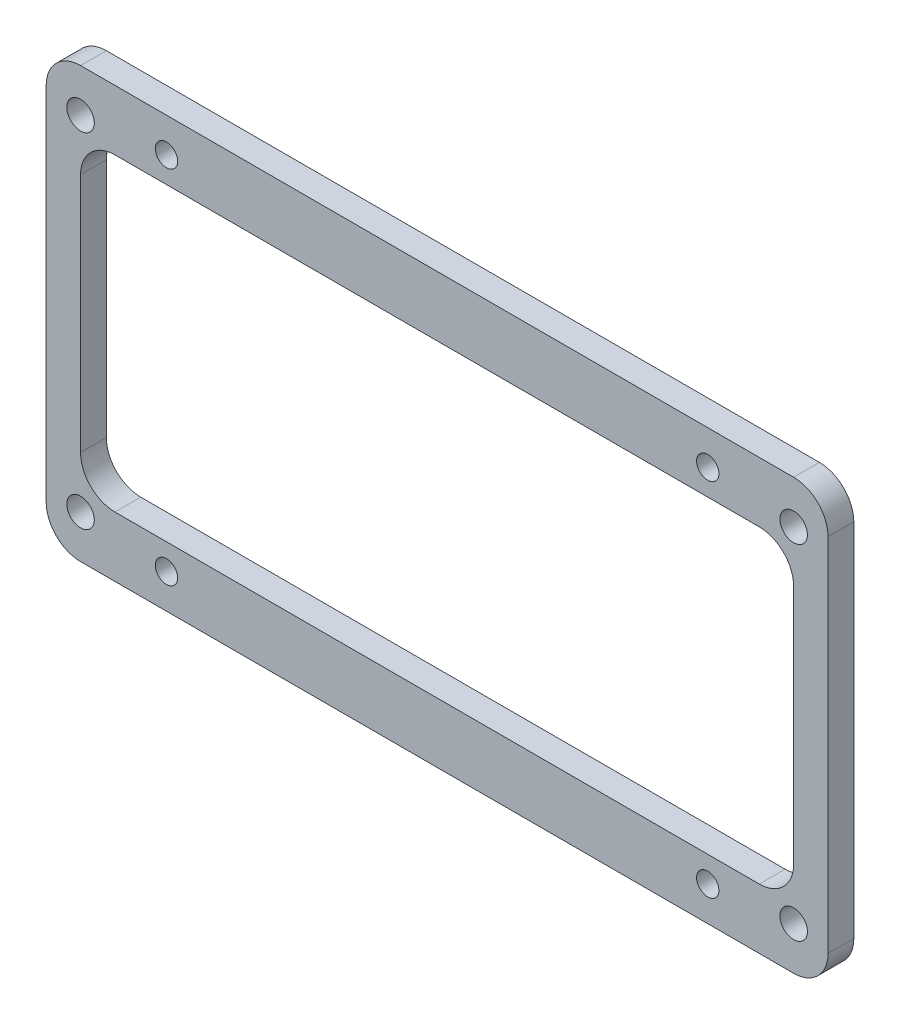
from build123d import *

# Parameters (mm, degrees)
SKETCH_1_W          = 91
SKETCH_1_H          = 50
SKETCH_1_W_2        = 83
SKETCH_1_H_2        = 36
EXTRUDE_1_DEPTH     = 3
SKETCH_2_R          = 1.3
CUT_EXTRUDE_1_DEPTH = 3
SKETCH_3_R          = 1.6
CUT_EXTRUDE_2_DEPTH = 3
FILLET_1_R          = 4
SKETCH_4_W          = 30
SKETCH_4_H          = 35
EXTRUDE_2_DEPTH     = 3
SKETCH_5_R          = 1.25
CUT_EXTRUDE_3_DEPTH = 10
FILLET_2_R          = 3
SKETCH_6_W          = 18
SKETCH_6_H          = 27
CUT_EXTRUDE_4_DEPTH = 10
FILLET_3_R          = 2
SKETCH_7_W          = 38
SKETCH_7_H          = 10
SKETCH_7_R          = 1.6
EXTRUDE_3_DEPTH     = 3
FILLET_4_R          = 2
FILLET_5_R          = 2
SKETCH_8_W          = 42
SKETCH_8_H          = 10
CUT_EXTRUDE_5_DEPTH = 10
SKETCH_9_W          = 30
SKETCH_9_H          = 41
CUT_EXTRUDE_6_DEPTH = 10


with BuildPart() as part:
    # 草图1 → 凸台-拉伸1 (new body)
    with BuildSketch(Plane.XY):
        Rectangle(SKETCH_1_W, SKETCH_1_H)
        Rectangle(SKETCH_1_W_2, SKETCH_1_H_2, mode=Mode.SUBTRACT)
    extrude(amount=EXTRUDE_1_DEPTH)

    # 草图2 → 切除-拉伸1 (cut)
    with BuildSketch(Plane.XY.offset(3)):
        with Locations((31.5, 21)):
            Circle(SKETCH_2_R)
        with Locations((31.5, -21)):
            Circle(SKETCH_2_R)
        with Locations((-31.5, -21)):
            Circle(SKETCH_2_R)
        with Locations((-31.5, 21)):
            Circle(SKETCH_2_R)
    extrude(amount=-CUT_EXTRUDE_1_DEPTH, mode=Mode.SUBTRACT)

    # 草图3 → 切除-拉伸2 (cut)
    with BuildSketch(Plane.XY.offset(3)):
        with Locations((41.5, 20)):
            Circle(SKETCH_3_R)
        with Locations((41.5, -20)):
            Circle(SKETCH_3_R)
        with Locations((-41.5, -20)):
            Circle(SKETCH_3_R)
        with Locations((-41.5, 20)):
            Circle(SKETCH_3_R)
    extrude(amount=-CUT_EXTRUDE_2_DEPTH, mode=Mode.SUBTRACT)

    # 圆角1
    fillet_1_edges = [part.edges().sort_by_distance(p)[0] for p in [
        (41.5, -18, 1.5),
        (41.5, 18, 1.5),
        (-41.5, 18, 1.5),
        (-41.5, -18, 1.5),
        (45.5, -25, 1.5),
        (-45.5, -25, 1.5),
        (-45.5, 25, 1.5),
        (45.5, 25, 1.5),
    ]]
    fillet(fillet_1_edges, radius=FILLET_1_R)

    # 草图4 → 凸台-拉伸2 (add)
    with BuildSketch(Plane(origin=(0, 0, 0), x_dir=(-1, 0, 0), z_dir=(0, 0, -1))):
        with Locations((-60.5, 0)):
            Rectangle(SKETCH_4_W, SKETCH_4_H)
    extrude(amount=-EXTRUDE_2_DEPTH)

    # 草图5 → 切除-拉伸3 (cut)
    with BuildSketch(Plane(origin=(0, 0, 0), x_dir=(-1, 0, 0), z_dir=(0, 0, -1))):
        with Locations((-70.5, -12)):
            Circle(SKETCH_5_R)
        with Locations((-70.5, 12)):
            Circle(SKETCH_5_R)
    extrude(amount=-CUT_EXTRUDE_3_DEPTH, mode=Mode.SUBTRACT)

    # 圆角2
    fillet_2_edges = [part.edges().sort_by_distance(p)[0] for p in [
        (45.5, 17.5, 1.5),
        (45.5, -17.5, 1.5),
        (75.5, -17.5, 1.5),
        (75.5, 17.5, 1.5),
    ]]
    fillet(fillet_2_edges, radius=FILLET_2_R)

    # 草图6 → 切除-拉伸4 (cut)
    with BuildSketch(Plane(origin=(0, 0, 0), x_dir=(-1, 0, 0), z_dir=(0, 0, -1))):
        with Locations((-57.5, 0)):
            Rectangle(SKETCH_6_W, SKETCH_6_H)
    extrude(amount=-CUT_EXTRUDE_4_DEPTH, mode=Mode.SUBTRACT)

    # 圆角3
    fillet_3_edges = [part.edges().sort_by_distance(p)[0] for p in [
        (66.5, -13.5, 1.5),
        (66.5, 13.5, 1.5),
        (48.5, 13.5, 1.5),
        (48.5, -13.5, 1.5),
    ]]
    fillet(fillet_3_edges, radius=FILLET_3_R)

    # 草图7 → 凸台-拉伸3 (add)
    with BuildSketch(Plane(origin=(0, 0, 0), x_dir=(-1, 0, 0), z_dir=(0, 0, -1))):
        with Locations((0, 30)):
            Rectangle(SKETCH_7_W, SKETCH_7_H)
        with Locations((-16, 32)):
            Circle(SKETCH_7_R, mode=Mode.SUBTRACT)
        with Locations((16, 32)):
            Circle(SKETCH_7_R, mode=Mode.SUBTRACT)
        with Locations((0, -30)):
            Rectangle(SKETCH_7_W, SKETCH_7_H)
        with Locations((16, -32)):
            Circle(SKETCH_7_R, mode=Mode.SUBTRACT)
        with Locations((-16, -32)):
            Circle(SKETCH_7_R, mode=Mode.SUBTRACT)
    extrude(amount=-EXTRUDE_3_DEPTH)

    # 圆角4
    fillet_4_edges = [part.edges().sort_by_distance(p)[0] for p in [
        (19, 35, 1.5),
        (-19, 35, 1.5),
        (-19, -35, 1.5),
        (19, -35, 1.5),
    ]]
    fillet(fillet_4_edges, radius=FILLET_4_R)

    # 圆角5
    fillet_5_edges = [part.edges().sort_by_distance(p)[0] for p in [
        (19, 25, 1.5),
        (-19, 25, 1.5),
        (-19, -25, 1.5),
        (19, -25, 1.5),
    ]]
    fillet(fillet_5_edges, radius=FILLET_5_R)

    # 草图8 → 切除-拉伸5 (cut)
    with BuildSketch(Plane.XY.offset(3)):
        with Locations((0, 30)):
            Rectangle(SKETCH_8_W, SKETCH_8_H)
        with Locations((0, -30)):
            Rectangle(SKETCH_8_W, SKETCH_8_H)
    extrude(amount=-CUT_EXTRUDE_5_DEPTH, mode=Mode.SUBTRACT)

    # 草图9 → 切除-拉伸6 (cut)
    with BuildSketch(Plane.XY.offset(3)):
        with Locations((60.5, 0)):
            Rectangle(SKETCH_9_W, SKETCH_9_H)
    extrude(amount=-CUT_EXTRUDE_6_DEPTH, mode=Mode.SUBTRACT)


solid = part.part
